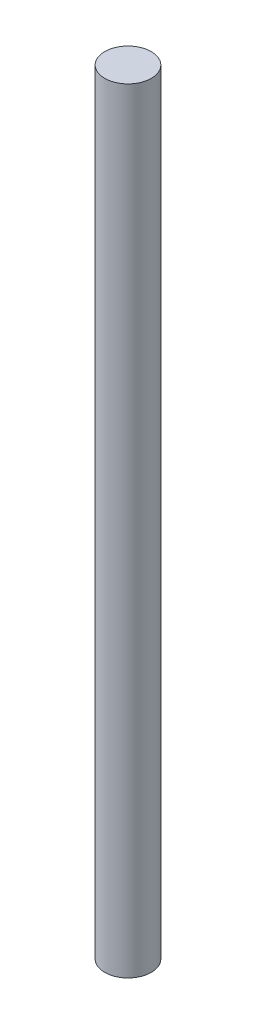
from build123d import *

# Parameters (mm, degrees)
CROQUIS1_R              = 3
SALIENTE_EXTRUIR1_DEPTH = 100


with BuildPart() as part:
    # Croquis1 → Saliente-Extruir1 (new body)
    with BuildSketch(Plane(origin=(0, 0, 0), x_dir=(1, 0, 0), z_dir=(0, 1, 0))):
        Circle(CROQUIS1_R)
    extrude(amount=SALIENTE_EXTRUIR1_DEPTH)


solid = part.part
